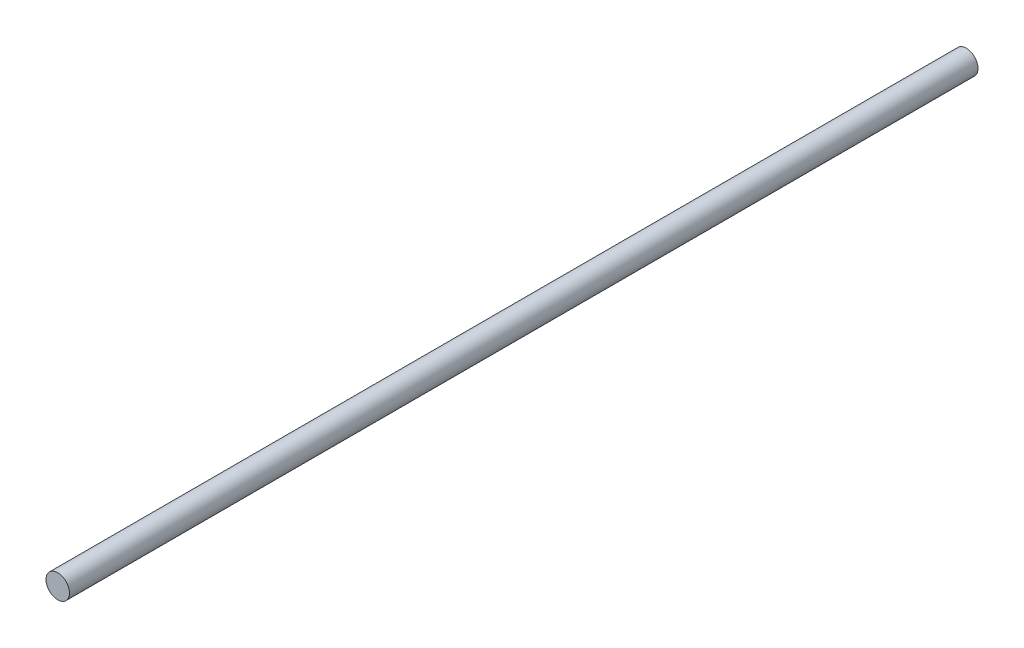
from build123d import *

# Parameters (mm, degrees)
SKETCH1_R           = 5
BOSS_EXTRUDE1_DEPTH = 387


with BuildPart() as part:
    # Sketch1 → Boss-Extrude1 (new body)
    with BuildSketch(Plane.XY):
        with Locations((-1.231707317, 13.73516158)):
            Circle(SKETCH1_R)
    extrude(amount=-BOSS_EXTRUDE1_DEPTH)


solid = part.part
